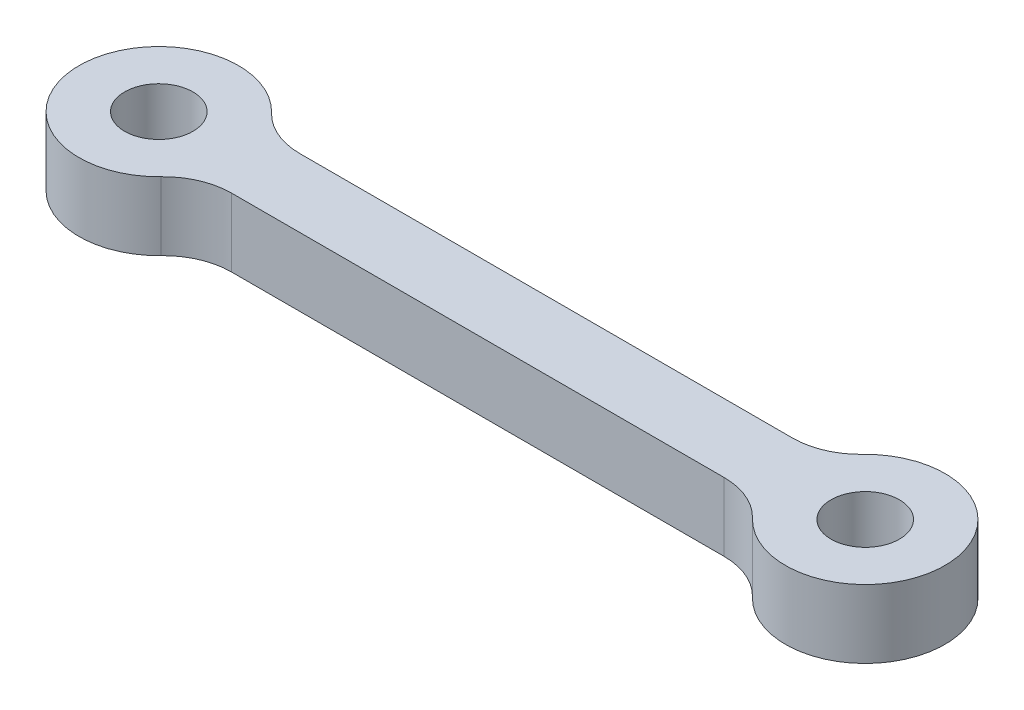
from build123d import *

# Parameters (mm, degrees)
SKETCH1_R           = 1.5
BOSS_EXTRUDE1_DEPTH = 3
FILLET1_R           = 3


with BuildPart() as part:
    # Sketch1 → Boss-Extrude1 (new body)
    with BuildSketch(Plane(origin=(0, 0, 0), x_dir=(1, 0, 0), z_dir=(0, 1, 0))):
        with BuildLine():
            Line((-12.33772234, 1.5), (12.33772234, 1.5))
            ThreePointArc((12.33772234, 1.5), (19, 0), (12.33772234, -1.5))
            Line((12.33772234, -1.5), (-12.33772234, -1.5))
            ThreePointArc((-12.33772234, -1.5), (-19, 0), (-12.33772234, 1.5))
        make_face()
        with Locations((-15.5, 0)):
            Circle(SKETCH1_R, mode=Mode.SUBTRACT)
        with Locations((15.5, 0)):
            Circle(SKETCH1_R, mode=Mode.SUBTRACT)
    extrude(amount=BOSS_EXTRUDE1_DEPTH)

    # Fillet1
    fillet1_edges = [part.edges().sort_by_distance(p)[0] for p in [
        (-12.33772234, 1.5, -1.5),
        (12.33772234, 1.5, -1.5),
        (12.33772234, 1.5, 1.5),
        (-12.33772234, 1.5, 1.5),
    ]]
    fillet(fillet1_edges, radius=FILLET1_R)


solid = part.part
